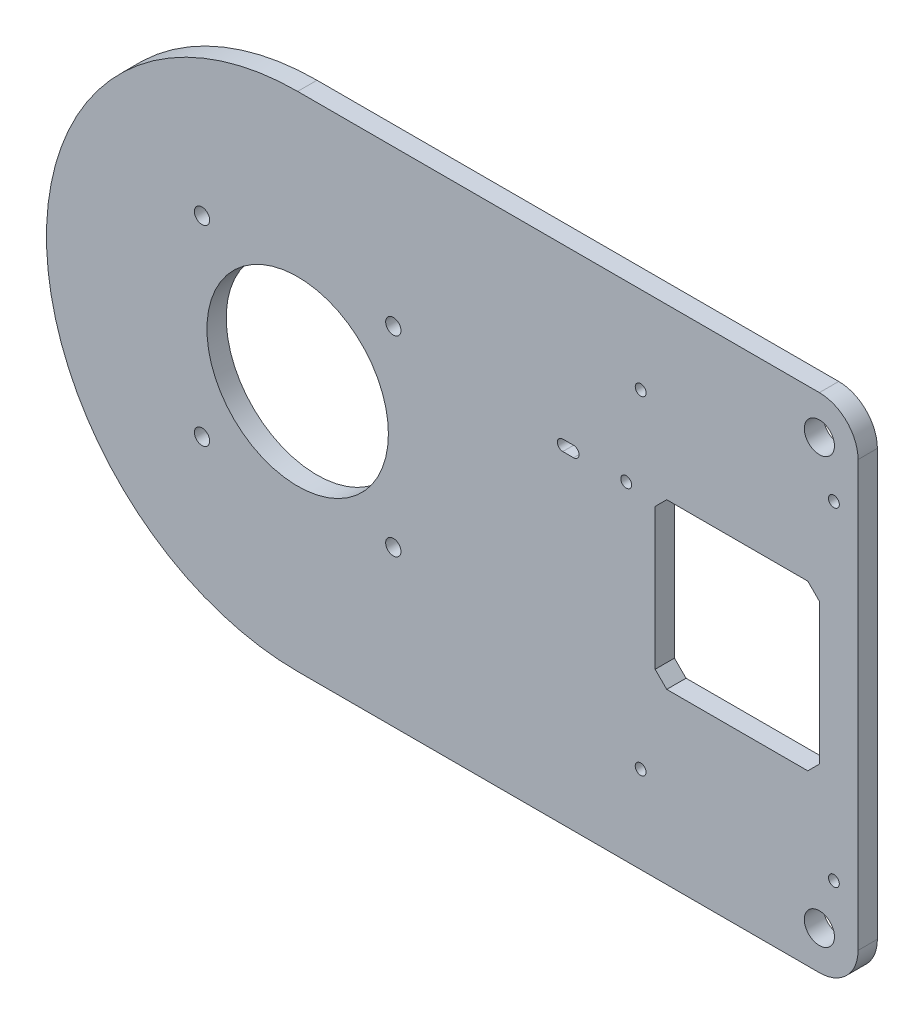
from build123d import *

# Parameters (mm, degrees)
SKETCH1_R           = 3.9
SKETCH1_R_2         = 23.48
SKETCH1_R_3         = 1.975
SKETCH1_R_4         = 1.4
BOSS_EXTRUDE4_DEPTH = 5


with BuildPart() as part:
    # Sketch1 → Boss-Extrude4 (new body)
    with BuildSketch(Plane.XY):
        with BuildLine():
            Line((-40, -65), (95, -65))
            ThreePointArc((95, -65), (102.071067812, -62.071067812), (105, -55))
            Line((105, -55), (105, 55))
            ThreePointArc((105, 55), (102.071067812, 62.071067812), (95, 65))
            Line((95, 65), (-40, 65))
            ThreePointArc((-40, 65), (-105, 0), (-40, -65))
        make_face()
        with Locations((95, 55)):
            Circle(SKETCH1_R, mode=Mode.SUBTRACT)
        with Locations((95, -55)):
            Circle(SKETCH1_R, mode=Mode.SUBTRACT)
        with Locations((-40, 0)):
            Circle(SKETCH1_R_2, mode=Mode.SUBTRACT)
        with Locations((-64.75, 24.75)):
            Circle(SKETCH1_R_3, mode=Mode.SUBTRACT)
        with Locations((-15.25, 24.75)):
            Circle(SKETCH1_R_3, mode=Mode.SUBTRACT)
        with Locations((-15.25, -24.75)):
            Circle(SKETCH1_R_3, mode=Mode.SUBTRACT)
        with Locations((-64.75, -24.75)):
            Circle(SKETCH1_R_3, mode=Mode.SUBTRACT)
        with Locations((98.75, 42.5)):
            Circle(SKETCH1_R_4, mode=Mode.SUBTRACT)
        with Locations((48.75, 42.5)):
            Circle(SKETCH1_R_4, mode=Mode.SUBTRACT)
        with Locations((48.75, -42.5)):
            Circle(SKETCH1_R_4, mode=Mode.SUBTRACT)
        with Locations((98.75, -42.5)):
            Circle(SKETCH1_R_4, mode=Mode.SUBTRACT)
        with Locations((45, 20)):
            Circle(SKETCH1_R_4, mode=Mode.SUBTRACT)
        Polygon((95, 18.25), (95, -18.25), (92, -21.25), (55.5, -21.25), (52.5, -18.25), (52.5, 18.25), (55.5, 21.25), (92, 21.25), align=None, mode=Mode.SUBTRACT)
        with BuildLine():
            Line((28.6, 21.4), (31.4, 21.4))
            ThreePointArc((31.4, 21.4), (32.8, 20), (31.4, 18.6))
            Line((31.4, 18.6), (28.6, 18.6))
            ThreePointArc((28.6, 18.6), (27.2, 20), (28.6, 21.4))
        make_face(mode=Mode.SUBTRACT)
    extrude(amount=BOSS_EXTRUDE4_DEPTH)


solid = part.part
